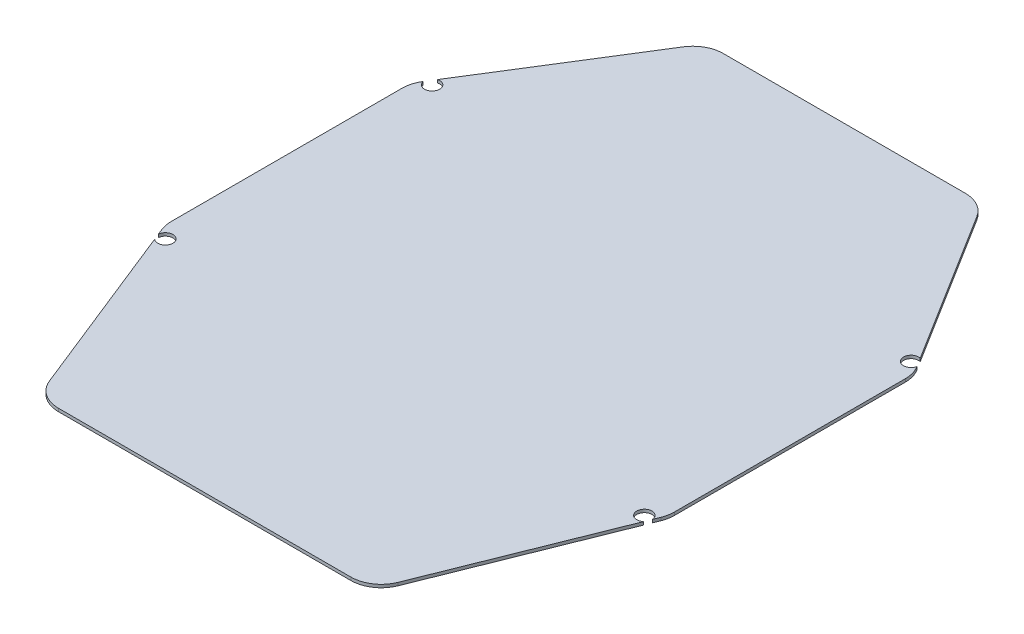
from build123d import *

# Parameters (mm, degrees)
BOSS_EXTRUDE1_DEPTH = 1
SKETCH2_R           = 2.5
CUT_EXTRUDE1_DEPTH  = 1


with BuildPart() as part:
    # Sketch1 → Boss-Extrude1 (new body)
    with BuildSketch(Plane(origin=(0, 0, 0), x_dir=(1, 0, 0), z_dir=(0, 1, 0))):
        with BuildLine():
            Line((83, -33.574175964), (83, 42.632037736))
            ThreePointArc((83, 42.632037736), (82.612487462, 45.388862866), (81.47998304, 47.932027136))
            Line((81.47998304, 47.932027136), (48.437506625, 100.7999894))
            ThreePointArc((48.437506625, 100.7999894), (44.805208909, 104.246424812), (39.957523585, 105.5))
            Line((39.957523585, 105.5), (-39.957523585, 105.5))
            ThreePointArc((-39.957523585, 105.5), (-44.805208909, 104.246424812), (-48.437506625, 100.7999894))
            Line((-48.437506625, 100.7999894), (-81.47998304, 47.932027136))
            ThreePointArc((-81.47998304, 47.932027136), (-82.612487462, 45.388862866), (-83, 42.632037736))
            Line((-83, 42.632037736), (-83, -33.574175964))
            ThreePointArc((-83, -33.574175964), (-82.819563867, -35.465251176), (-82.284766909, -37.288082728))
            Line((-82.284766909, -37.288082728), (-57.514437295, -99.213906764))
            ThreePointArc((-57.514437295, -99.213906764), (-53.835958479, -103.780672305), (-48.229670386, -105.5))
            Line((-48.229670386, -105.5), (48.229670386, -105.5))
            ThreePointArc((48.229670386, -105.5), (53.835958479, -103.780672305), (57.514437295, -99.213906764))
            Line((57.514437295, -99.213906764), (82.284766909, -37.288082728))
            ThreePointArc((82.284766909, -37.288082728), (82.819563867, -35.465251176), (83, -33.574175964))
        make_face()
    extrude(amount=BOSS_EXTRUDE1_DEPTH)

    # Sketch2 → Cut-Extrude1 (cut)
    with BuildSketch(Plane(origin=(0, 1, 0), x_dir=(1, 0, 0), z_dir=(0, 1, 0))):
        with Locations((79, 48.528930886)):
            Circle(SKETCH2_R)
        with Locations((79, -39.471069114)):
            Circle(SKETCH2_R)
        with Locations((-79, 48.528930886)):
            Circle(SKETCH2_R)
        with Locations((-79, -39.471069114)):
            Circle(SKETCH2_R)
    extrude(amount=-CUT_EXTRUDE1_DEPTH, mode=Mode.SUBTRACT)


solid = part.part
